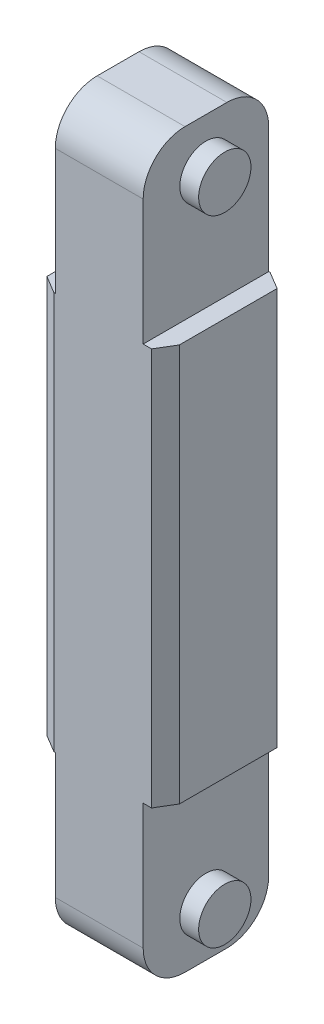
from build123d import *

# Parameters (mm, degrees)
SKETCH1_W             = 120
SKETCH1_H             = 120
BOSS_EXTRUDE1_DEPTH   = 700
SKETCH2_W             = 18
SKETCH2_H             = 120
CUT_EXTRUDE1_DEPTH    = 160
SKETCH3_R             = 26.228524845
BOSS_EXTRUDE2_DEPTH   = 18
SKETCH4_R             = 25
BOSS_EXTRUDE3_DEPTH   = 18
FILLET1_R             = 40
SKETCH5_W             = 18
SKETCH5_H             = 120
CUT_EXTRUDE2_DEPTH    = 160
SKETCH6_R             = 25
BOSS_EXTRUDE5_DEPTH   = 18
SKETCH7_R             = 25
BOSS_EXTRUDE6_DEPTH   = 18
FILLET2_R             = 40
CHAMFER1_SIZE         = 10
CHAMFER1_SIZE2        = 16.642794824
CHAMFER1_PART_2_SIZE  = 10
CHAMFER1_PART_2_SIZE2 = 16.642794824
CHAMFER1_PART_3_SIZE  = 10
CHAMFER1_PART_3_SIZE2 = 16.642794824
CHAMFER1_PART_4_SIZE  = 10
CHAMFER1_PART_4_SIZE2 = 16.642794824


with BuildPart() as part:
    # Sketch1 → Boss-Extrude1 (new body)
    with BuildSketch(Plane(origin=(0, 0, 0), x_dir=(1, 0, 0), z_dir=(0, 1, 0))):
        Rectangle(SKETCH1_W, SKETCH1_H)
    extrude(amount=BOSS_EXTRUDE1_DEPTH)

    # Sketch2 → Cut-Extrude1 (cut)
    with BuildSketch(Plane.XZ):
        with Locations((-51, 0)):
            Rectangle(SKETCH2_W, SKETCH2_H)
        with Locations((51, 0)):
            Rectangle(SKETCH2_W, SKETCH2_H)
    extrude(amount=-CUT_EXTRUDE1_DEPTH, mode=Mode.SUBTRACT)

    # Sketch3 → Boss-Extrude2 (add)
    with BuildSketch(Plane.ZY.offset(42)):
        with Locations((0, 47.02)):
            Circle(SKETCH3_R)
    extrude(amount=BOSS_EXTRUDE2_DEPTH)

    # Sketch4 → Boss-Extrude3 (add)
    with BuildSketch(Plane(origin=(42, 0, 0), x_dir=(0, 0, -1), z_dir=(1, 0, 0))):
        with Locations((0, 47.02)):
            Circle(SKETCH4_R)
    extrude(amount=BOSS_EXTRUDE3_DEPTH)

    # Fillet1
    fillet1_edges = [part.edges().sort_by_distance(p)[0] for p in [
        (0, 0, 60),
        (0, 0, -60),
    ]]
    fillet(fillet1_edges, radius=FILLET1_R)

    # Sketch5 → Cut-Extrude2 (cut)
    with BuildSketch(Plane(origin=(0, 700, 0), x_dir=(1, 0, 0), z_dir=(0, 1, 0))):
        with Locations((-51, 0)):
            Rectangle(SKETCH5_W, SKETCH5_H)
        with Locations((51, 0)):
            Rectangle(SKETCH5_W, SKETCH5_H)
    extrude(amount=-CUT_EXTRUDE2_DEPTH, mode=Mode.SUBTRACT)

    # Sketch6 → Boss-Extrude5 (add)
    with BuildSketch(Plane.ZY.offset(42)):
        with Locations((0, 652.98)):
            Circle(SKETCH6_R)
    extrude(amount=BOSS_EXTRUDE5_DEPTH)

    # Sketch7 → Boss-Extrude6 (add)
    with BuildSketch(Plane(origin=(42, 0, 0), x_dir=(0, 0, -1), z_dir=(1, 0, 0))):
        with Locations((0, 652.98)):
            Circle(SKETCH7_R)
    extrude(amount=BOSS_EXTRUDE6_DEPTH)

    # Fillet2
    fillet2_edges = [part.edges().sort_by_distance(p)[0] for p in [
        (0, 700, -60),
        (0, 700, 60),
    ]]
    fillet(fillet2_edges, radius=FILLET2_R)

    # Chamfer1
    chamfer1_edges = [part.edges().sort_by_distance(p)[0] for p in [
        (60, 350, 60),
    ]]
    chamfer1_side = [part.faces().sort_by_distance(p)[0] for p in [
        (0, 350, 60),
    ]]
    chamfer(chamfer1_edges, length=CHAMFER1_SIZE, length2=CHAMFER1_SIZE2, reference=chamfer1_side[0])

    # Chamfer1 part 2
    chamfer1_part_2_edges = [part.edges().sort_by_distance(p)[0] for p in [
        (-60, 350, 60),
    ]]
    chamfer1_part_2_side = [part.faces().sort_by_distance(p)[0] for p in [
        (-60, 350, 0),
    ]]
    chamfer(chamfer1_part_2_edges, length=CHAMFER1_PART_2_SIZE, length2=CHAMFER1_PART_2_SIZE2, reference=chamfer1_part_2_side[0])

    # Chamfer1 part 3
    chamfer1_part_3_edges = [part.edges().sort_by_distance(p)[0] for p in [
        (-60, 350, -60),
    ]]
    chamfer1_part_3_side = [part.faces().sort_by_distance(p)[0] for p in [
        (0, 350, -60),
    ]]
    chamfer(chamfer1_part_3_edges, length=CHAMFER1_PART_3_SIZE, length2=CHAMFER1_PART_3_SIZE2, reference=chamfer1_part_3_side[0])

    # Chamfer1 part 4
    chamfer1_part_4_edges = [part.edges().sort_by_distance(p)[0] for p in [
        (60, 350, -60),
    ]]
    chamfer1_part_4_side = [part.faces().sort_by_distance(p)[0] for p in [
        (60, 350, 0),
    ]]
    chamfer(chamfer1_part_4_edges, length=CHAMFER1_PART_4_SIZE, length2=CHAMFER1_PART_4_SIZE2, reference=chamfer1_part_4_side[0])


solid = part.part
